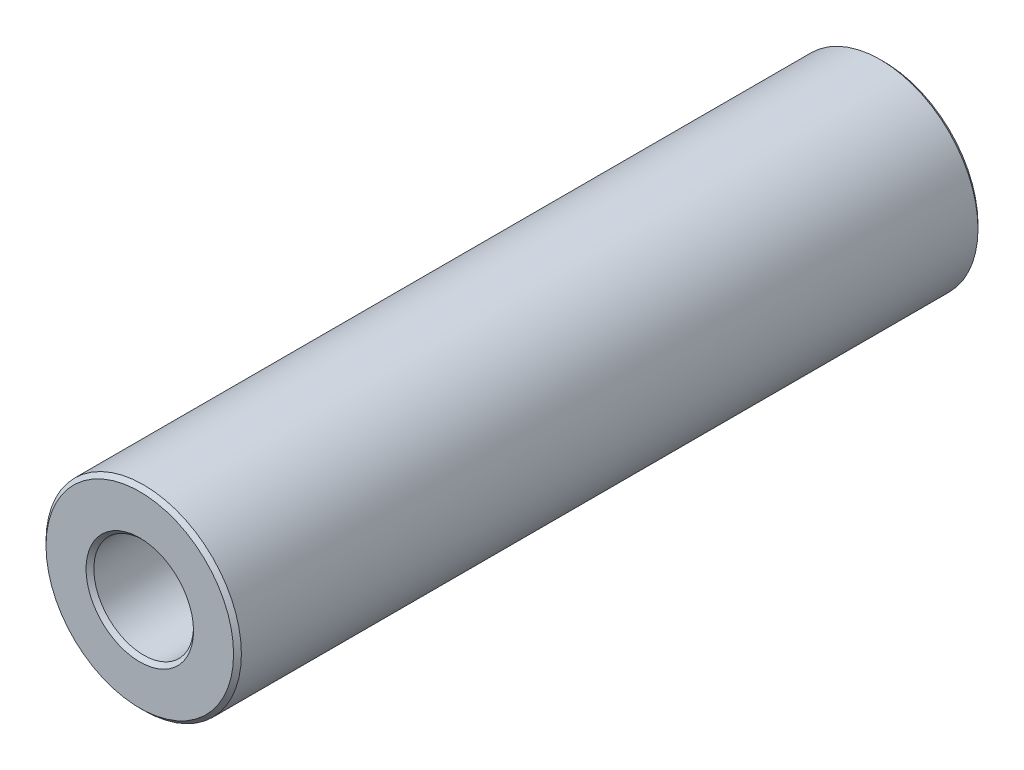
from build123d import *

# Parameters (mm, degrees)
SKETCH1_R           = 5
SKETCH1_R_2         = 2.55
BOSS_EXTRUDE1_DEPTH = 38.1
CHAMFER1_SIZE       = 0.2


with BuildPart() as part:
    # Sketch1 → Boss-Extrude1 (new body)
    with BuildSketch(Plane.XY):
        Circle(SKETCH1_R)
        Circle(SKETCH1_R_2, mode=Mode.SUBTRACT)
    extrude(amount=BOSS_EXTRUDE1_DEPTH)

    # Chamfer1
    chamfer1_edges = [part.edges().sort_by_distance(p)[0] for p in [
        (-5, 0, 0),
        (-5, 0, 38.1),
        (-2.55, 0, 0),
        (-2.55, 0, 38.1),
    ]]
    chamfer(chamfer1_edges, length=CHAMFER1_SIZE)


solid = part.part
